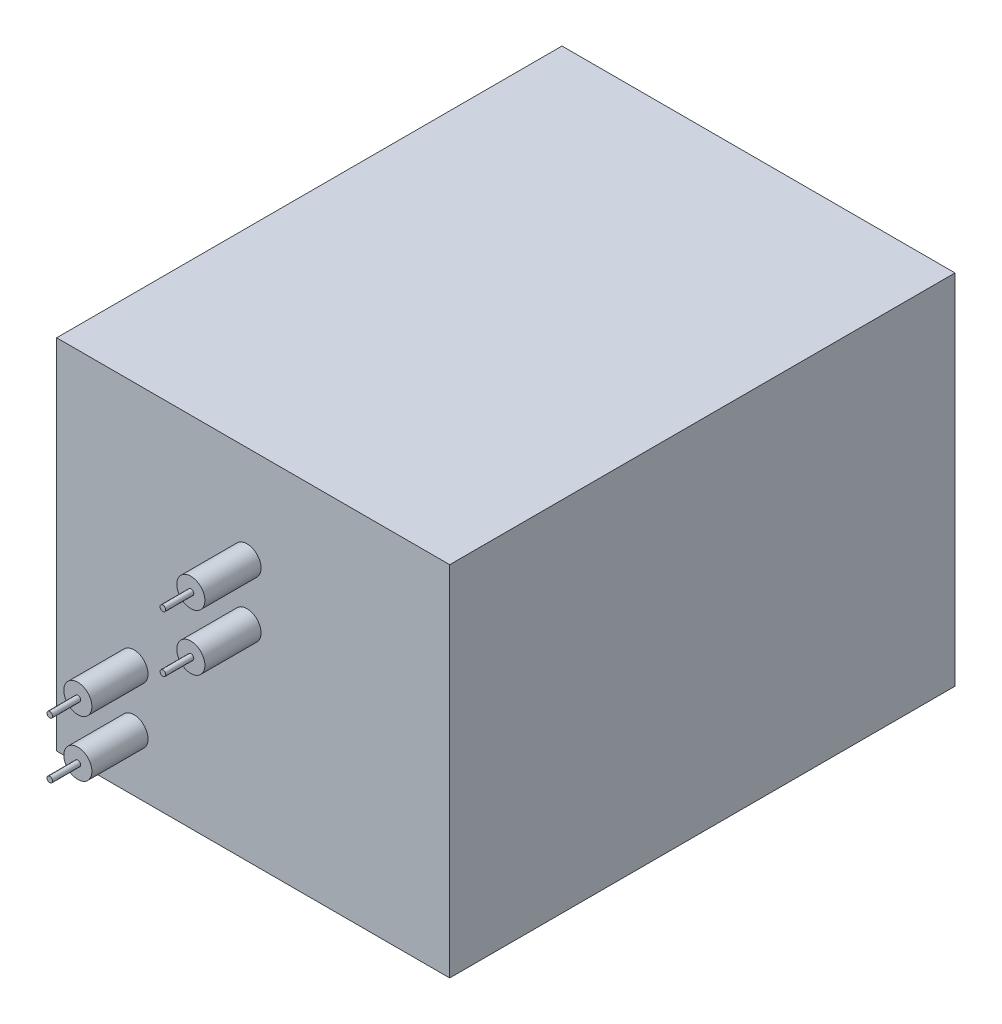
from build123d import *

# Parameters (mm, degrees)
SKETCH1_W           = 177.8
SKETCH1_H           = 228.6
BOSS_EXTRUDE1_DEPTH = 161.925
SKETCH2_R           = 6.35
BOSS_EXTRUDE2_DEPTH = 25.4
SKETCH4_R           = 6.35
BOSS_EXTRUDE4_DEPTH = 25.4
LPATTERN1_COUNT     = 2
LPATTERN1_PITCH     = 25.4
LPATTERN2_COUNT     = 2
LPATTERN2_PITCH     = 25.4
SKETCH5_R           = 1.27
BOSS_EXTRUDE5_DEPTH = 12.7
LPATTERN3_COUNT     = 2
LPATTERN3_PITCH     = 25.4
SKETCH6_R           = 1.27
BOSS_EXTRUDE6_DEPTH = 12.7
LPATTERN4_COUNT     = 2
LPATTERN4_PITCH     = 25.4


with BuildPart() as part:
    # Sketch1 → Boss-Extrude1 (new body)
    with BuildSketch(Plane(origin=(0, 0, 0), x_dir=(1, 0, 0), z_dir=(0, 1, 0))):
        Rectangle(SKETCH1_W, SKETCH1_H)
    extrude(amount=BOSS_EXTRUDE1_DEPTH)

    # Sketch2 → Boss-Extrude2 (add)
    with BuildSketch(Plane.XY.offset(114.3)):
        with Locations((-2.792336917, 117.907265363)):
            Circle(SKETCH2_R)
    boss_extrude2 = extrude(amount=BOSS_EXTRUDE2_DEPTH)

    # Sketch4 → Boss-Extrude4 (add)
    with BuildSketch(Plane.XY.offset(114.3)):
        with Locations((-53.913582013, 25.4)):
            Circle(SKETCH4_R)
    boss_extrude4 = extrude(amount=BOSS_EXTRUDE4_DEPTH)

    # LPattern1: Boss-Extrude2 ×2
    with Locations(*[(0, -i * LPATTERN1_PITCH, 0) for i in range(1, LPATTERN1_COUNT)]):
        add(boss_extrude2)

    # LPattern2: Boss-Extrude4 ×2
    with Locations(*[(0, i * LPATTERN2_PITCH, 0) for i in range(1, LPATTERN2_COUNT)]):
        add(boss_extrude4)

    # Sketch5 → Boss-Extrude5 (add)
    with BuildSketch(Plane.XY.offset(139.7)):
        with Locations((-2.730512125, 118.079738131)):
            Circle(SKETCH5_R)
    boss_extrude5 = extrude(amount=BOSS_EXTRUDE5_DEPTH)

    # LPattern3: Boss-Extrude5 ×2
    with Locations(*[(0, -i * LPATTERN3_PITCH, 0) for i in range(1, LPATTERN3_COUNT)]):
        add(boss_extrude5)

    # Sketch6 → Boss-Extrude6 (add)
    with BuildSketch(Plane.XY.offset(139.7)):
        with Locations((-53.913582013, 50.8)):
            Circle(SKETCH6_R)
    boss_extrude6 = extrude(amount=BOSS_EXTRUDE6_DEPTH)

    # LPattern4: Boss-Extrude6 ×2
    with Locations(*[(0, -i * LPATTERN4_PITCH, 0) for i in range(1, LPATTERN4_COUNT)]):
        add(boss_extrude6)


solid = part.part
